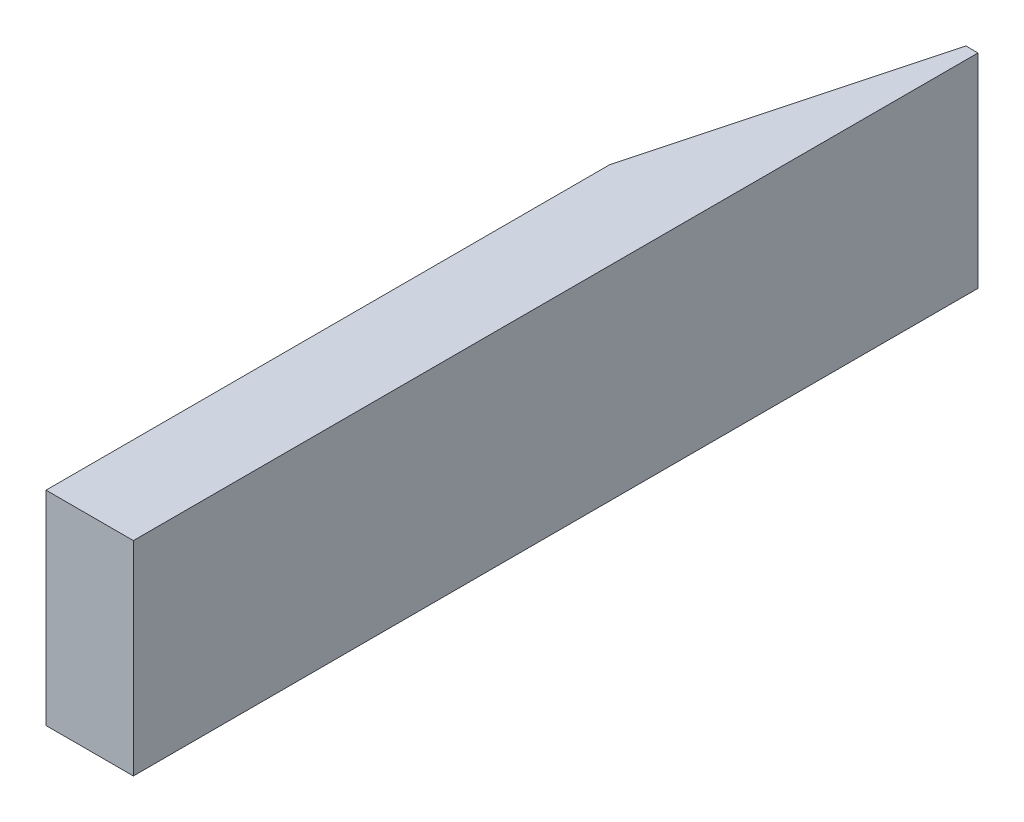
from build123d import *

# Parameters (mm, degrees)
SKETCH1_W           = 38.1
SKETCH1_H           = 88.9
BOSS_EXTRUDE1_DEPTH = 368.3
CHAMFER1_SIZE       = 32.86
CHAMFER1_SIZE2      = 122.635189537


with BuildPart() as part:
    # Sketch1 → Boss-Extrude1 (new body)
    with BuildSketch(Plane.XY):
        with Locations((19.05, 44.45)):
            Rectangle(SKETCH1_W, SKETCH1_H)
    extrude(amount=BOSS_EXTRUDE1_DEPTH)

    # Chamfer1
    chamfer1_edges = [part.edges().sort_by_distance(p)[0] for p in [
        (0, 44.45, 0),
    ]]
    chamfer1_side = [part.faces().sort_by_distance(p)[0] for p in [
        (19.05, 44.45, 0),
    ]]
    chamfer(chamfer1_edges, length=CHAMFER1_SIZE, length2=CHAMFER1_SIZE2, reference=chamfer1_side[0])


solid = part.part
